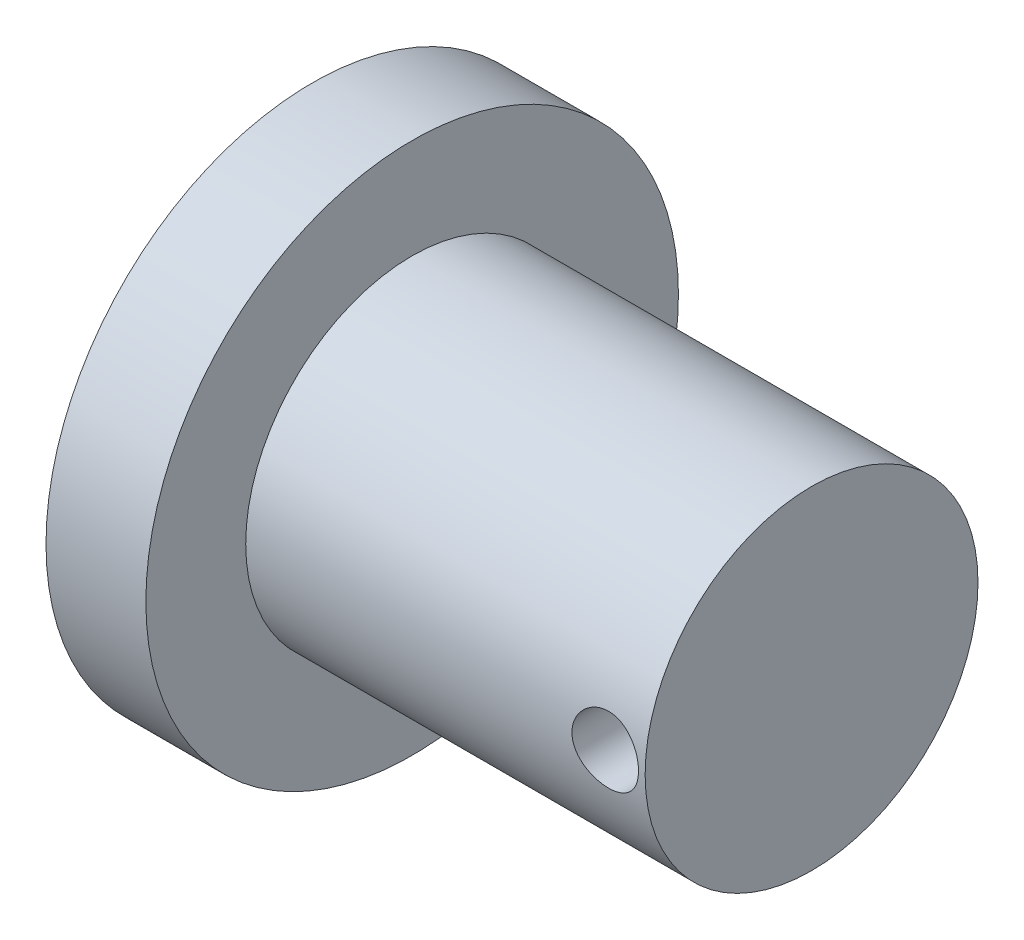
from build123d import *

# Parameters (mm, degrees)
SKETCH3_R               = 1
CUT_EXTRUDE1_DEPTH      = 9
CUT_EXTRUDE1_DEPTH_BACK = 9


with BuildPart() as part:
    # Sketch2 → Revolve1 (revolve)
    with BuildSketch(Plane.XY):
        Polygon((-25.088495575, 0), (-10.088495575, 0), (-10.088495575, 5), (-22.088495575, 5), (-22.088495575, 8), (-25.088495575, 8), align=None)
    revolve(axis=Axis((-25.088495575, 0, 0), (1, 0, 0)))

    # Sketch3 → Cut-Extrude1 (cut, two sides)
    with BuildSketch(Plane.XY) as cut_extrude1_sk:
        with Locations((-11.288495575, 0)):
            Circle(SKETCH3_R)
    extrude(amount=CUT_EXTRUDE1_DEPTH, mode=Mode.SUBTRACT)
    extrude(cut_extrude1_sk.sketch, amount=-CUT_EXTRUDE1_DEPTH_BACK, mode=Mode.SUBTRACT)


solid = part.part
